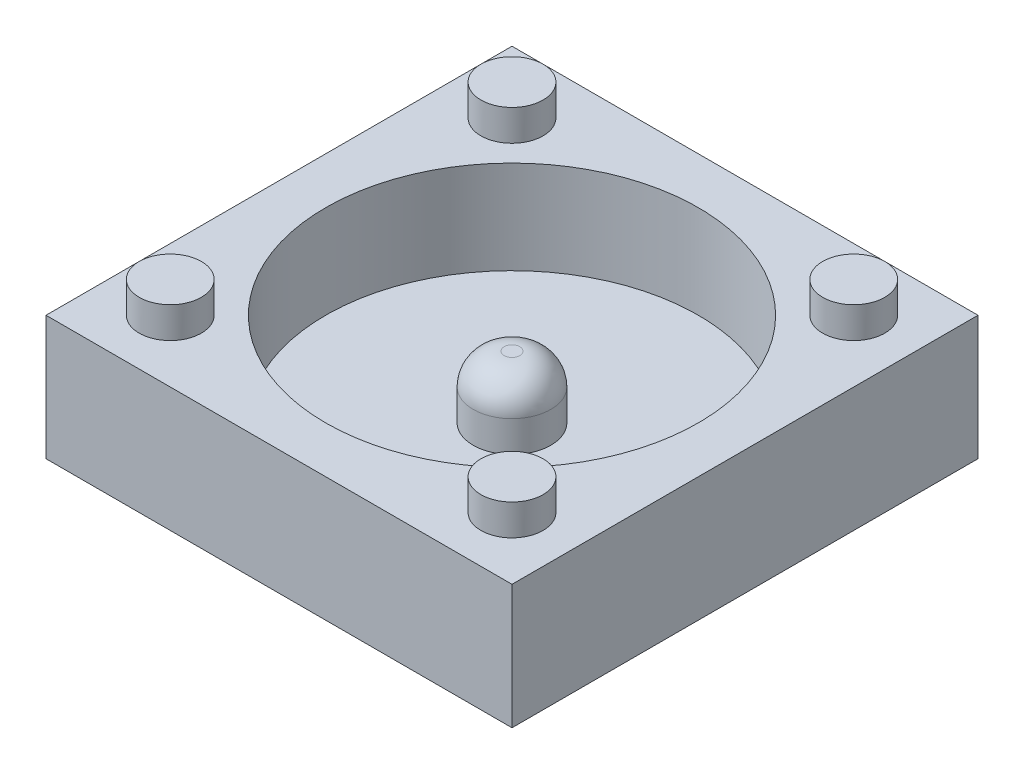
from build123d import *

# Parameters (mm, degrees)
SKETCH1_W           = 15
SKETCH1_H           = 15
BOSS_EXTRUDE2_DEPTH = 4
SKETCH4_R           = 6
CUT_EXTRUDE4_DEPTH  = 3
SKETCH5_R           = 1.25
BOSS_EXTRUDE3_DEPTH = 2
FILLET2_R           = 1
SKETCH6_R           = 1
BOSS_EXTRUDE4_DEPTH = 1


with BuildPart() as part:
    # Sketch1 → Boss-Extrude2 (new body)
    with BuildSketch(Plane(origin=(0, 0, 0), x_dir=(1, 0, 0), z_dir=(0, 1, 0))):
        Rectangle(SKETCH1_W, SKETCH1_H)
    extrude(amount=BOSS_EXTRUDE2_DEPTH)

    # Sketch4 → Cut-Extrude4 (cut)
    with BuildSketch(Plane(origin=(0, 4, 0), x_dir=(1, 0, 0), z_dir=(0, 1, 0))):
        Circle(SKETCH4_R)
    extrude(amount=-CUT_EXTRUDE4_DEPTH, mode=Mode.SUBTRACT)

    # Sketch5 → Boss-Extrude3 (add)
    with BuildSketch(Plane(origin=(0, 1, 0), x_dir=(1, 0, 0), z_dir=(0, 1, 0))):
        Circle(SKETCH5_R)
    extrude(amount=BOSS_EXTRUDE3_DEPTH)

    # Fillet2
    fillet2_edges = [part.edges().sort_by_distance(p)[0] for p in [
        (-1.25, 3, 0),
    ]]
    fillet(fillet2_edges, radius=FILLET2_R)

    # Sketch6 → Boss-Extrude4 (add)
    with BuildSketch(Plane(origin=(0, 4, 0), x_dir=(1, 0, 0), z_dir=(0, 1, 0))):
        with Locations((-5.5, 5.5)):
            Circle(SKETCH6_R)
        with Locations((5.5, 5.5)):
            Circle(SKETCH6_R)
        with Locations((-5.5, -5.5)):
            Circle(SKETCH6_R)
        with Locations((5.5, -5.5)):
            Circle(SKETCH6_R)
    extrude(amount=BOSS_EXTRUDE4_DEPTH)


solid = part.part
